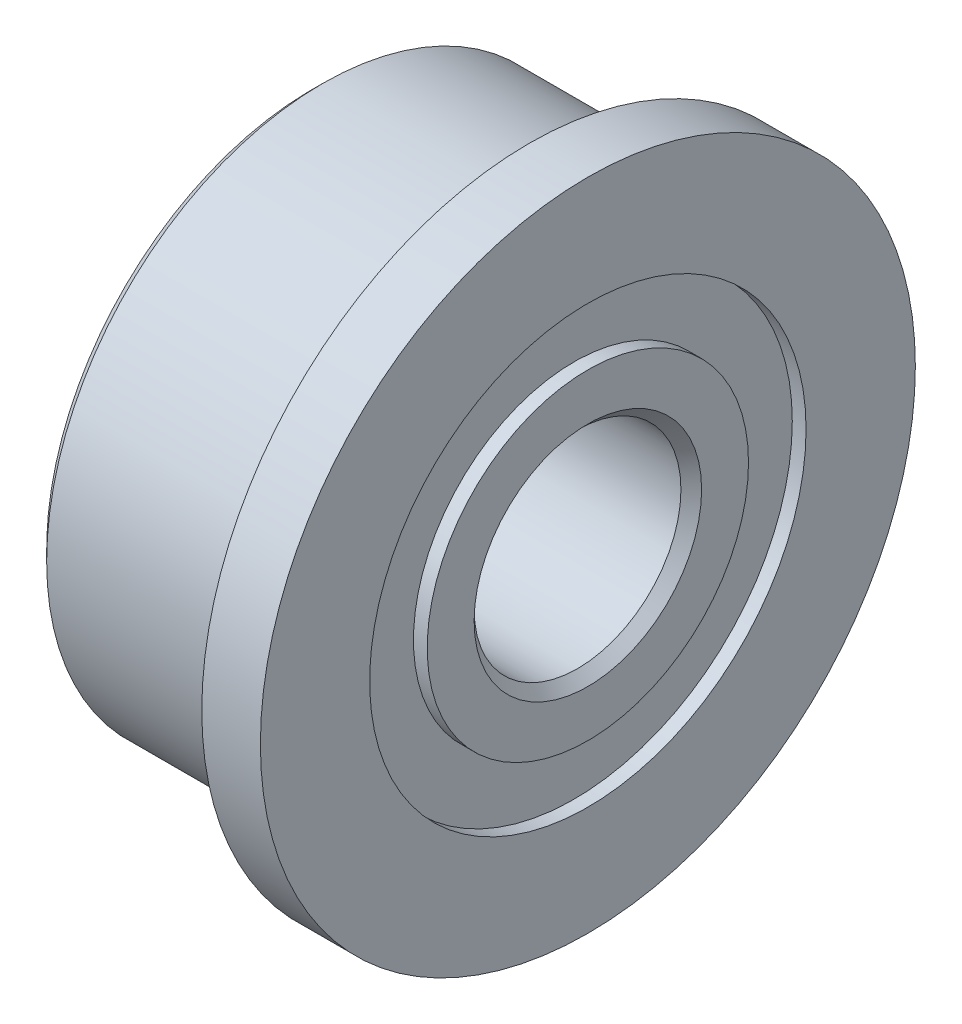
from build123d import *


with BuildPart() as part:
    # Schizzo1 → Rivoluzione1 (revolve)
    with BuildSketch(Plane.XY):
        with BuildLine():
            Line((-3.8, 3.165), (-3.8, 2.33))
            Line((-3.8, 2.33), (-4, 2.33))
            Line((-4, 2.33), (-4, 1.65))
            Line((-4, 1.65), (-3.85, 1.5))
            Line((-3.85, 1.5), (-0.15, 1.5))
            Line((-0.15, 1.5), (0, 1.65))
            Line((0, 1.65), (0, 2.33))
            Line((0, 2.33), (-0.2, 2.33))
            Line((-0.2, 2.33), (-0.2, 3.165))
            Line((-0.2, 3.165), (0, 3.165))
            Line((0, 3.165), (0, 4.75))
            Line((0, 4.75), (-0.85, 4.75))
            Line((-0.85, 4.75), (-0.85, 4.02))
            ThreePointArc((-0.85, 4.02), (-0.835857864, 3.985857864), (-0.87, 4))
            Line((-0.87, 4), (-3.85, 4))
            Line((-3.85, 4), (-4, 3.85))
            Line((-4, 3.85), (-4, 3.165))
            Line((-4, 3.165), (-3.8, 3.165))
        make_face()
    revolve(axis=Axis((-4, 0, 0), (1, 0, 0)))


solid = part.part
